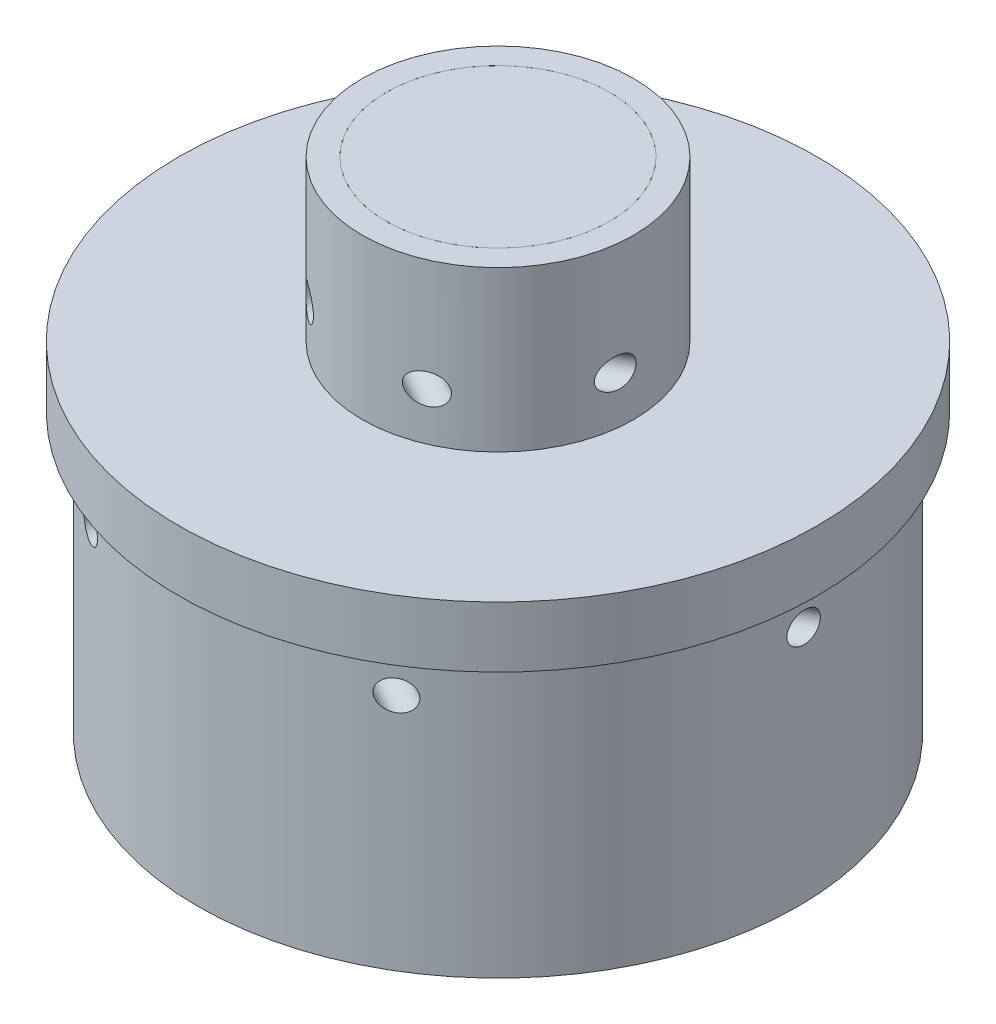
from build123d import *

# Parameters (mm, degrees)
SKETCH3_W          = 4.445
SKETCH3_H          = 3.175
CIRPATTERN11_COUNT = 6
CIRPATTERN10_COUNT = 6


with BuildPart() as part:
    # Sketch1 → Revolve1 (revolve)
    with BuildSketch(Plane.XY):
        Polygon((-5.3975, 0), (-5.3975, -6.35), (-12.7, -6.35), (-12.7, -8.763), (-6.35, -8.763), (-6.35, -9.525), (-4.60375, -9.525), (-4.60375, -15.135366794), (-3.33375, -15.661418018), (-3.33375, -17.671051224), (-2.54, -17.671051224), (-2.54, -15.131051224), (-3.81, -14.605), (-3.81, -3.175), (-4.445, -3.175), (-4.445, 0), align=None)
    revolve(axis=Axis((0, -1.5875, 0), (0, -1, 0)))

    # Sketch5 → 3_64 _0.04688_ Diameter Hole1 (revolve, cut)
    with BuildSketch(Plane(origin=(-3.2146875, -4.445, 0), x_dir=(0, 1, 0), z_dir=(1, 0, 0))):
        Polygon((0, 0), (0, 16.359737992), (0.595376, 16.002), (0.595376, 0), align=None)
    f_3_64_0_04688_diameter_hole1 = revolve(axis=Axis((-3.2146875, -4.445, -6.35), (0, 0, 1)), mode=Mode.SUBTRACT)

    # CirPattern11: 3_64 _0.04688_ Diameter Hole1 ×6 about axis
    cirpattern11_axis = Axis((0, 42.935, 0), (0, -1, 0))
    for i in range(1, CIRPATTERN11_COUNT):
        add(f_3_64_0_04688_diameter_hole1.rotate(cirpattern11_axis, i * 360 / CIRPATTERN11_COUNT), mode=Mode.SUBTRACT)


with BuildPart() as body_2:
    # Sketch2 → Revolve2 (revolve)
    with BuildSketch(Plane.XY):
        Polygon((-6.35, -9.525), (-6.35, -15.875), (-4.445, -16.664076836), (-4.445, -23.014076836), (-6.35, -23.014076836), (-6.35, -19.839076836), (-7.3152, -19.839076836), (-7.3152, -17.857876836), (-10.3886, -17.857876836), (-10.3886, -19.839076836), (-11.938, -19.839076836), (-11.938, -8.763), (-6.35, -8.763), align=None)
    revolve(axis=Axis((0, -1.5875, 0), (0, -1, 0)))

    # Sketch7 → 3_64 _0.04688_ Diameter Hole2 (revolve, cut)
    with BuildSketch(Plane(origin=(-5.7546875, -10.3505, 0), x_dir=(0, 1, 0), z_dir=(1, 0, 0))):
        Polygon((0, 0), (0, 16.359737992), (0.595376, 16.002), (0.595376, 0), align=None)
    f_3_64_0_04688_diameter_hole2 = revolve(axis=Axis((-5.7546875, -10.3505, -6.35), (0, 0, 1)), mode=Mode.SUBTRACT)

    # CirPattern10: 3_64 _0.04688_ Diameter Hole2 ×6 about axis
    cirpattern10_axis = Axis((0, 42.935, 0), (0, -1, 0))
    for i in range(1, CIRPATTERN10_COUNT):
        add(f_3_64_0_04688_diameter_hole2.rotate(cirpattern10_axis, i * 360 / CIRPATTERN10_COUNT), mode=Mode.SUBTRACT)


with BuildPart() as body_3:
    # Sketch3 → Revolve3 (revolve)
    with BuildSketch(Plane.XY):
        with Locations((-2.2225, -1.5875)):
            Rectangle(SKETCH3_W, SKETCH3_H)
    revolve(axis=Axis((0, -3.175, 0), (0, 1, 0)))


solid = Compound([part.part, body_2.part, body_3.part])
